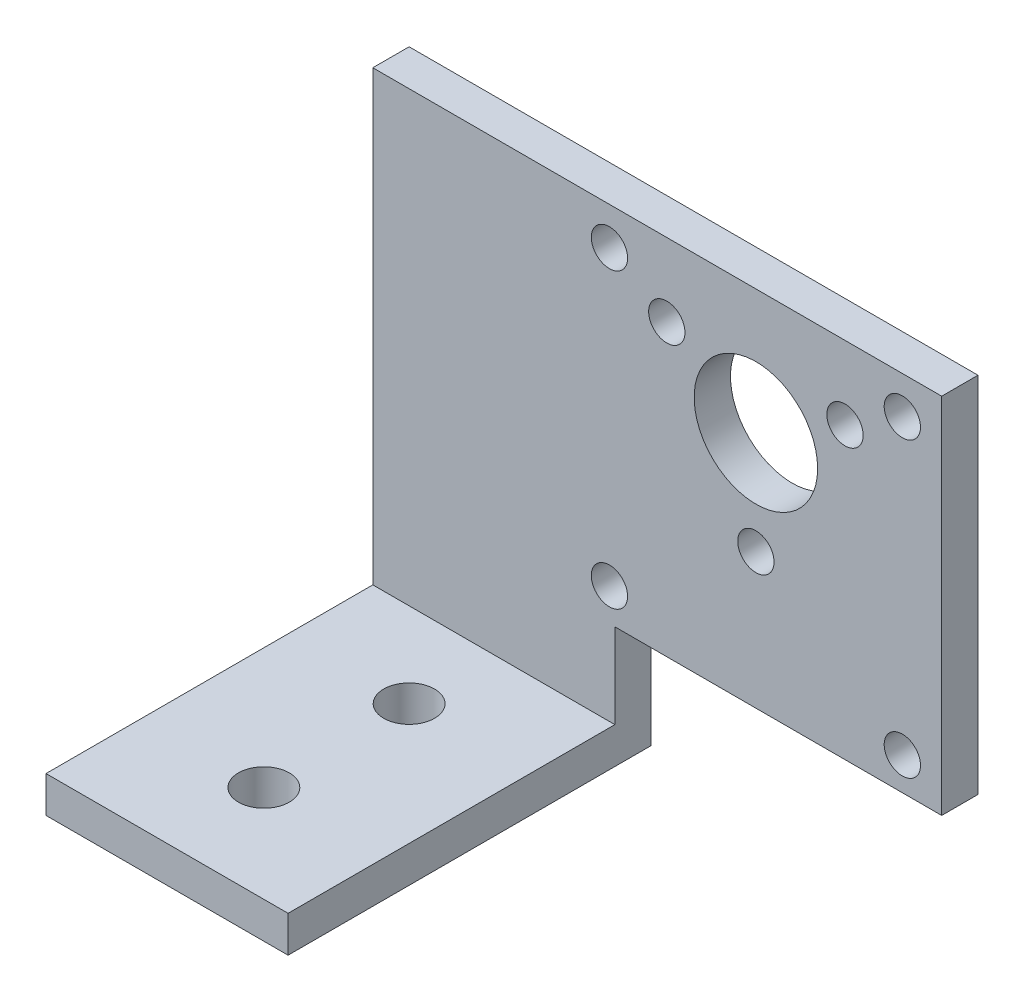
from build123d import *

# Parameters (mm, degrees)
ESQUISSE1_R             = 5.1
ESQUISSE1_R_2           = 1.5
EXTRUSION1_DEPTH        = 3
ESQUISSE2_W             = 20
ESQUISSE2_H             = 3
EXTRUSION2_DEPTH        = 27
ESQUISSE4_R             = 2.1
ENL_V_MAT_EXTRU_1_DEPTH = 4


with BuildPart() as part:
    # Esquisse1 → Extrusion1 (new body)
    with BuildSketch(Plane.XY):
        Polygon((-11.65, -19.7), (15.35, -19.7), (15.35, 10.3), (-31.65, 10.3), (-31.65, -29.7), (-11.65, -29.7), align=None)
        Circle(ESQUISSE1_R, mode=Mode.SUBTRACT)
        with Locations((-12.1, 7.2)):
            Circle(ESQUISSE1_R_2, mode=Mode.SUBTRACT)
        with Locations((-12.1, -17)):
            Circle(ESQUISSE1_R_2, mode=Mode.SUBTRACT)
        with Locations((12.1, -17)):
            Circle(ESQUISSE1_R_2, mode=Mode.SUBTRACT)
        with Locations((12.1, 7.2)):
            Circle(ESQUISSE1_R_2, mode=Mode.SUBTRACT)
        with Locations((0, -8.5)):
            Circle(ESQUISSE1_R_2, mode=Mode.SUBTRACT)
        with Locations((-7.361215932, 4.25)):
            Circle(ESQUISSE1_R_2, mode=Mode.SUBTRACT)
        with Locations((7.361215932, 4.25)):
            Circle(ESQUISSE1_R_2, mode=Mode.SUBTRACT)
    extrude(amount=EXTRUSION1_DEPTH)

    # Esquisse2 → Extrusion2 (add)
    with BuildSketch(Plane.XY.offset(3)):
        with Locations((-21.65, -28.2)):
            Rectangle(ESQUISSE2_W, ESQUISSE2_H)
    extrude(amount=EXTRUSION2_DEPTH)

    # Esquisse4 → Enlèv. mat.-Extru.1 (cut, through all)
    with BuildSketch(Plane(origin=(0, -26.7, 0), x_dir=(-1, 0, 0), z_dir=(0, 1, 0))):
        with Locations(Location((21.65, 10, 0), (0, 0, 90))):  # turned: the seam where the file's is
            Circle(ESQUISSE4_R)
        with Locations(Location((21.65, 22, 0), (0, 0, 90))):  # turned: the seam where the file's is
            Circle(ESQUISSE4_R)
    extrude(amount=-ENL_V_MAT_EXTRU_1_DEPTH, mode=Mode.SUBTRACT)


solid = part.part
